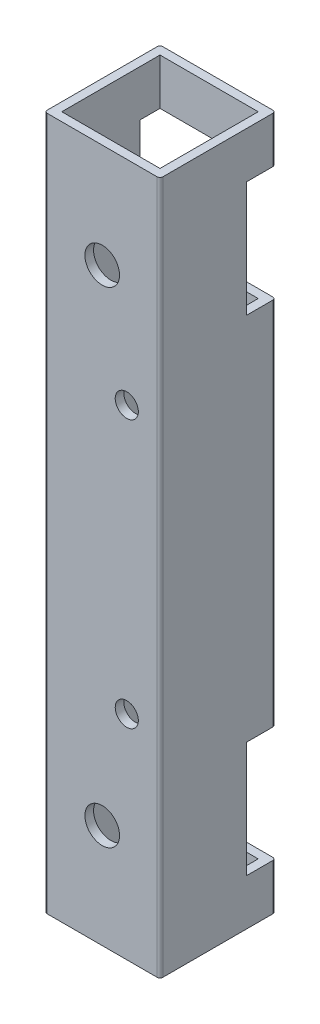
from build123d import *

# Parameters (mm, degrees)
SKETCH1_W           = 17
SKETCH1_H           = 17
BOSS_EXTRUDE1_DEPTH = 120
SKETCH2_W           = 5
SKETCH2_H           = 20
CUT_EXTRUDE1_DEPTH  = 124.288280059
SKETCH3_R           = 3
CUT_EXTRUDE2_DEPTH  = 100
SKETCH4_R           = 2
CUT_EXTRUDE3_DEPTH  = 10


with BuildPart() as part:
    # Sketch1 → Boss-Extrude1 (new body)
    with BuildSketch(Plane(origin=(0, 0, 0), x_dir=(1, 0, 0), z_dir=(0, 1, 0))):
        with BuildLine():
            Line((0.5, 0), (19.5, 0))
            ThreePointArc((19.5, 0), (19.853553391, 0.146446609), (20, 0.5))
            Line((20, 0.5), (20, 19.5))
            ThreePointArc((20, 19.5), (19.853553391, 19.853553391), (19.5, 20))
            Line((19.5, 20), (0.5, 20))
            ThreePointArc((0.5, 20), (0.146446609, 19.853553391), (0, 19.5))
            Line((0, 19.5), (0, 0.5))
            ThreePointArc((0, 0.5), (0.146446609, 0.146446609), (0.5, 0))
        make_face()
        with Locations((10, 10)):
            Rectangle(SKETCH1_W, SKETCH1_H, mode=Mode.SUBTRACT)
    extrude(amount=BOSS_EXTRUDE1_DEPTH)

    # Sketch2 → Cut-Extrude1 (cut, through all)
    with BuildSketch(Plane(origin=(20, 0, 0), x_dir=(0, 0, -1), z_dir=(1, 0, 0))):
        with Locations((17.5, 102)):
            Rectangle(SKETCH2_W, SKETCH2_H)
        with Locations((17.5, 18)):
            Rectangle(SKETCH2_W, SKETCH2_H)
    extrude(amount=-CUT_EXTRUDE1_DEPTH, mode=Mode.SUBTRACT)

    # Sketch3 → Cut-Extrude2 (cut)
    with BuildSketch(Plane.XY):
        with Locations((10, 102)):
            Circle(SKETCH3_R)
        with Locations((10, 18)):
            Circle(SKETCH3_R)
    extrude(amount=-CUT_EXTRUDE2_DEPTH, mode=Mode.SUBTRACT)

    # Sketch4 → Cut-Extrude3 (cut)
    with BuildSketch(Plane.XY):
        with Locations((14.25, 83.15)):
            Circle(SKETCH4_R)
        with Locations(Location((14.25, 36.85, 0), (0, 0, 180))):
            Circle(SKETCH4_R)
    extrude(amount=-CUT_EXTRUDE3_DEPTH, mode=Mode.SUBTRACT)


solid = part.part
